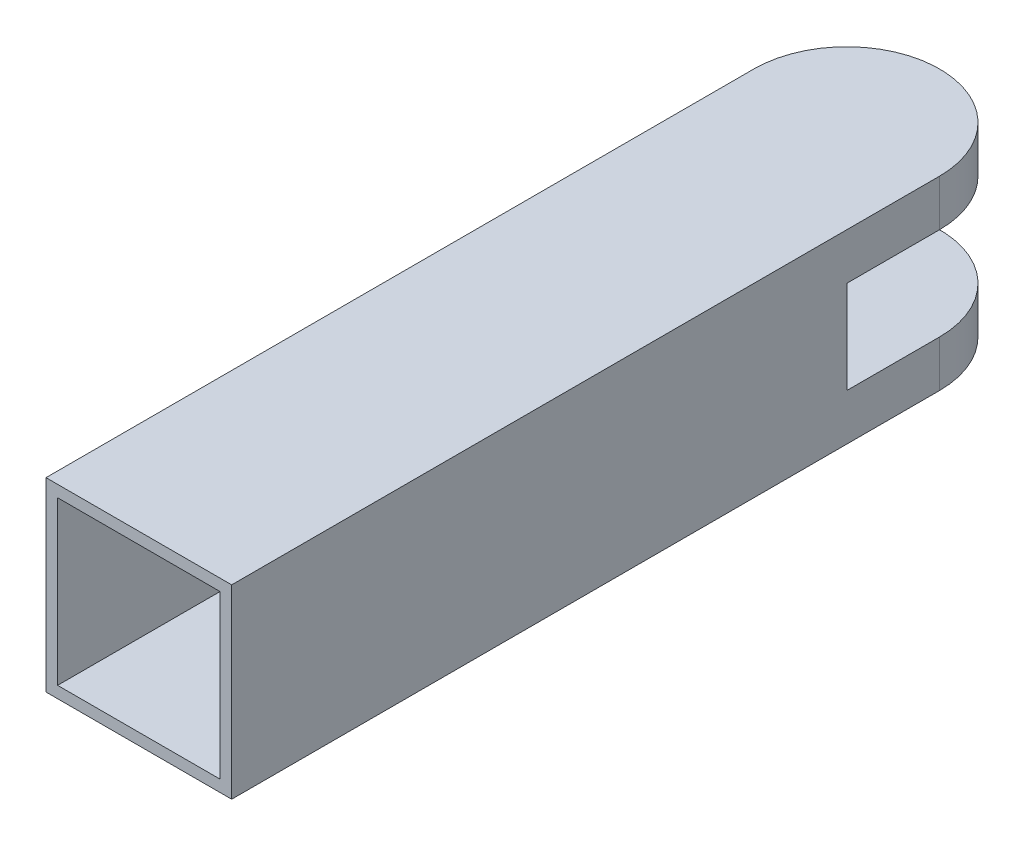
from build123d import *

# Parameters (mm, degrees)
SKETCH_1_W          = 16
SKETCH_1_H          = 16
SKETCH_1_W_2        = 14
SKETCH_1_H_2        = 14
EXTRUDE_1_DEPTH     = 52
SKETCH_2_W          = 16
SKETCH_2_H          = 16
EXTRUDE_2_DEPTH     = 1
SKETCH_3_W          = 16
SKETCH_3_H          = 16
EXTRUDE_3_DEPTH     = 16
CUT_EXTRUDE_1_DEPTH = 16
SKETCH_5_W          = 16
SKETCH_5_H          = 8
CUT_EXTRUDE_2_DEPTH = 17


with BuildPart() as part:
    # 草图1 → 凸台-拉伸1 (new body)
    with BuildSketch(Plane.XY):
        Rectangle(SKETCH_1_W, SKETCH_1_H)
        Rectangle(SKETCH_1_W_2, SKETCH_1_H_2, mode=Mode.SUBTRACT)
    extrude(amount=EXTRUDE_1_DEPTH)

    # 草图2 → 凸台-拉伸2 (add)
    with BuildSketch(Plane(origin=(0, 0, 0), x_dir=(-1, 0, 0), z_dir=(0, 0, -1))):
        Rectangle(SKETCH_2_W, SKETCH_2_H)
    extrude(amount=EXTRUDE_2_DEPTH)

    # 草图3 → 凸台-拉伸3 (add)
    with BuildSketch(Plane(origin=(0, 0, -1), x_dir=(-1, 0, 0), z_dir=(0, 0, -1))):
        Rectangle(SKETCH_3_W, SKETCH_3_H)
    extrude(amount=EXTRUDE_3_DEPTH)

    # 草图4 → 切除-拉伸1 (cut)
    with BuildSketch(Plane.XZ.offset(8)):
        with BuildLine():
            Line((-8, -9), (-8, -21.563953952))
            Line((-8, -21.563953952), (8, -21.563953952))
            Line((8, -21.563953952), (8, -9))
            ThreePointArc((8, -9), (0, -17), (-8, -9))
        make_face()
    extrude(amount=-CUT_EXTRUDE_1_DEPTH, mode=Mode.SUBTRACT)

    # 草图5 → 切除-拉伸2 (cut, through all)
    with BuildSketch(Plane(origin=(8, 0, 0), x_dir=(0, 0, -1), z_dir=(1, 0, 0))):
        with Locations((9, 0)):
            Rectangle(SKETCH_5_W, SKETCH_5_H)
    extrude(amount=-CUT_EXTRUDE_2_DEPTH, mode=Mode.SUBTRACT)


solid = part.part
